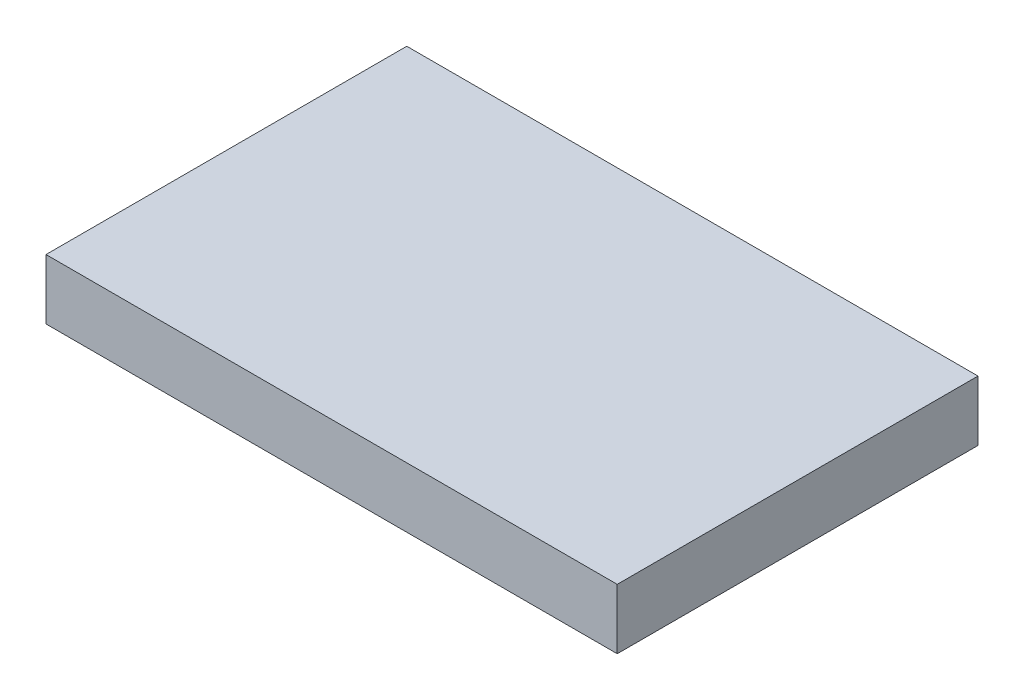
from build123d import *

# Parameters (mm, degrees)
SKETCH1_W           = 90.4875
SKETCH1_H           = 57.15
BOSS_EXTRUDE1_DEPTH = 9.525


with BuildPart() as part:
    # Sketch1 → Boss-Extrude1 (new body)
    with BuildSketch(Plane(origin=(0, 0, 0), x_dir=(1, 0, 0), z_dir=(0, 1, 0))):
        with Locations((45.24375, 28.575)):
            Rectangle(SKETCH1_W, SKETCH1_H)
    extrude(amount=BOSS_EXTRUDE1_DEPTH)


solid = part.part
